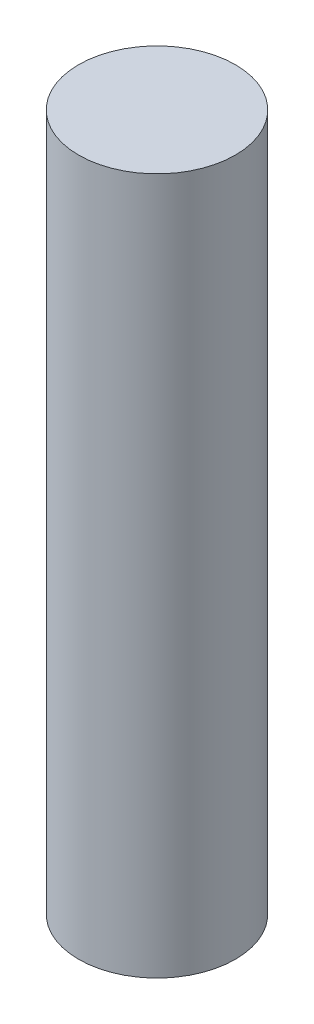
from build123d import *

# Parameters (mm, degrees)
SKETCH_1_R      = 2.25
EXTRUDE_1_DEPTH = 20


with BuildPart() as part:
    # 草图1 → 凸台-拉伸1 (new body)
    with BuildSketch(Plane(origin=(0, 0, 0), x_dir=(1, 0, 0), z_dir=(0, 1, 0))):
        Circle(SKETCH_1_R)
    extrude(amount=EXTRUDE_1_DEPTH)


solid = part.part
